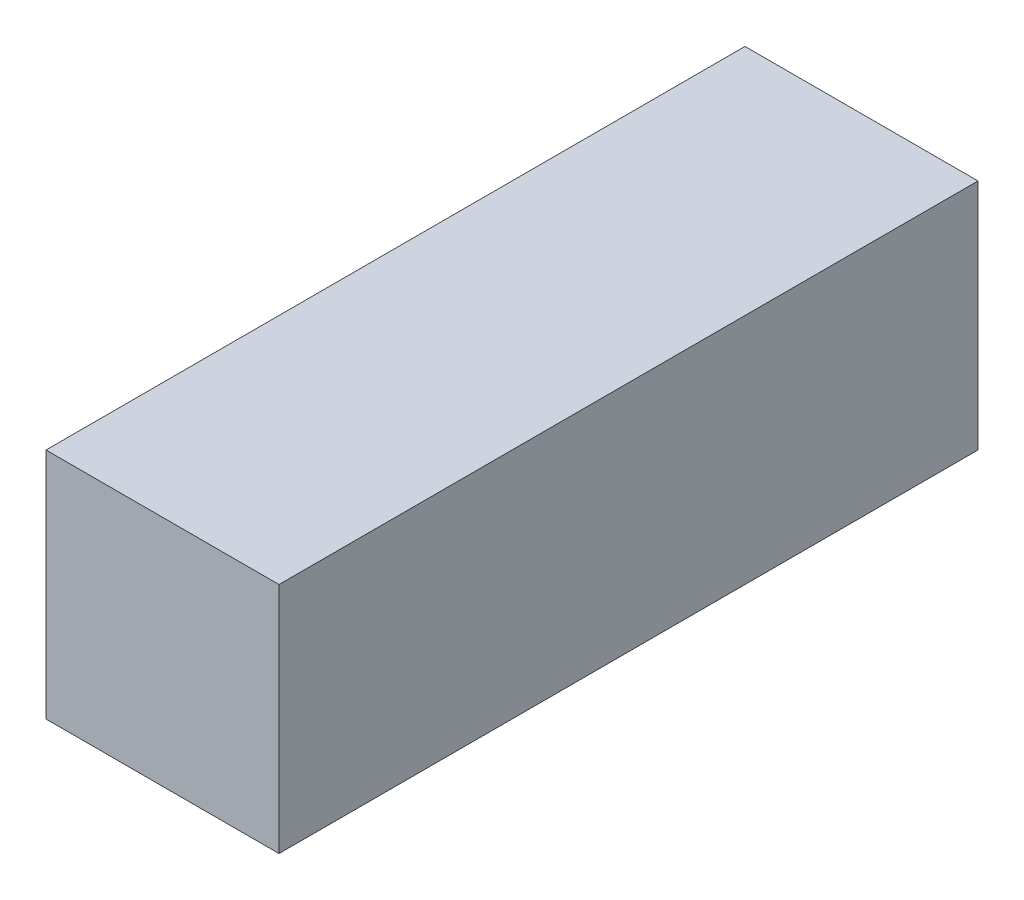
from build123d import *

# Parameters (mm, degrees)
SKETCH1_W           = 10
SKETCH1_H           = 30
BOSS_EXTRUDE1_DEPTH = 10


with BuildPart() as part:
    # Sketch1 → Boss-Extrude1 (new body)
    with BuildSketch(Plane(origin=(0, 0, 0), x_dir=(1, 0, 0), z_dir=(0, 1, 0))):
        Rectangle(SKETCH1_W, SKETCH1_H)
    extrude(amount=BOSS_EXTRUDE1_DEPTH)


solid = part.part
